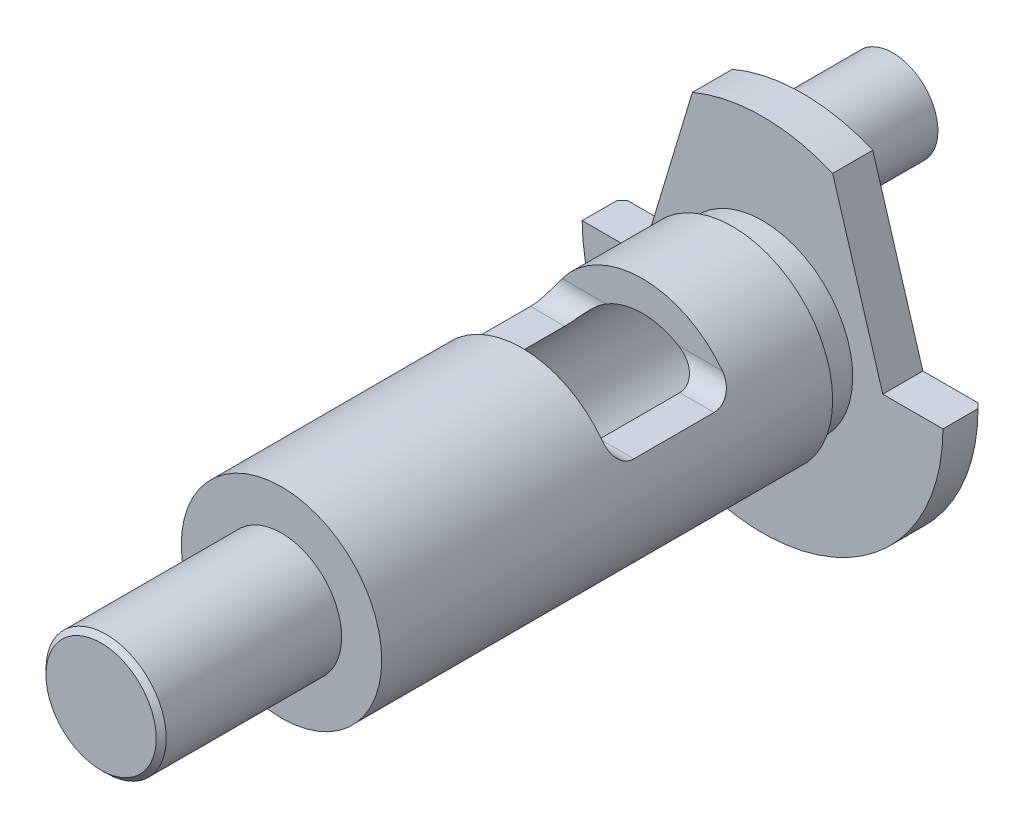
from build123d import *

# Parameters (mm, degrees)
ENL_V_MAT_EXTRU_1_DEPTH      = 19
ENL_V_MAT_EXTRU_1_DEPTH_BACK = 19
ESQUISSE4_OUTSIDE_W          = 55.312
ESQUISSE4_OUTSIDE_H          = 55.312
ENL_V_MAT_EXTRU_2_DEPTH      = 10
ESQUISSE5_R                  = 4.5
BOSS_EXTRU_1_DEPTH           = 9
CHANFREIN1_SIZE              = 0.5


with BuildPart() as part:
    # Esquisse2 → Révolution2 (revolve)
    with BuildSketch(Plane(origin=(0, 0, 0), x_dir=(0, 0, -1), z_dir=(1, 0, 0))):
        Polygon((-36, 0), (-70, 0), (-70, 6), (-52, 6), (-52, 10), (-7, 10), (-7, 9), (-4, 9), (-4, 18), (0, 18), (0, 7), (-32, 7), align=None)
    revolve(axis=Axis((0, 0, 0), (0, 0, 1)))

    # Esquisse3 → Enlèv. mat.-Extru.1 (cut, two sides)
    with BuildSketch(Plane(origin=(0, 0, 0), x_dir=(0, 0, -1), z_dir=(1, 0, 0))) as enl_v_mat_extru_1_sk:
        with BuildLine():
            Line((-16, 10), (-28, 10))
            Line((-28, 10), (-28, 6))
            ThreePointArc((-28, 6), (-27.414213562, 4.585786438), (-26, 4))
            Line((-26, 4), (-18, 4))
            ThreePointArc((-18, 4), (-16.585786438, 4.585786438), (-16, 6))
            Line((-16, 6), (-16, 10))
        make_face()
    extrude(amount=ENL_V_MAT_EXTRU_1_DEPTH, mode=Mode.SUBTRACT)
    extrude(enl_v_mat_extru_1_sk.sketch, amount=-ENL_V_MAT_EXTRU_1_DEPTH_BACK, mode=Mode.SUBTRACT)

    # Esquisse4 outside → Enlèv. mat.-Extru.2 (cut)
    with BuildSketch(Plane(origin=(0, 0, 0), x_dir=(-1, 0, 0), z_dir=(0, 0, -1))):
        Rectangle(ESQUISSE4_OUTSIDE_W, ESQUISSE4_OUTSIDE_H)
        with BuildLine():
            Line((-18, 0), (-12, 0))
            Line((-12, 0), (-7, 16.583123952))
            ThreePointArc((-7, 16.583123952), (0, 18), (7, 16.583123952))
            Line((7, 16.583123952), (12, 0))
            Line((12, 0), (18, 0))
            ThreePointArc((18, 0), (0, -18), (-18, 0))
        make_face(mode=Mode.SUBTRACT)
    extrude(amount=-ENL_V_MAT_EXTRU_2_DEPTH, mode=Mode.SUBTRACT)

    # Esquisse5 → Boss.-Extru.1 (add)
    with BuildSketch(Plane(origin=(0, 0, 0), x_dir=(-1, 0, 0), z_dir=(0, 0, -1))):
        with Locations((0, 12.5)):
            Circle(ESQUISSE5_R)
    extrude(amount=BOSS_EXTRU_1_DEPTH)

    # Chanfrein1
    chanfrein1_edges = [part.edges().sort_by_distance(p)[0] for p in [
        (4.5, 12.5, 0),
        (0, -6, 70),
        (0, -18, 0),
    ]]
    chamfer(chanfrein1_edges, length=CHANFREIN1_SIZE)


solid = part.part
